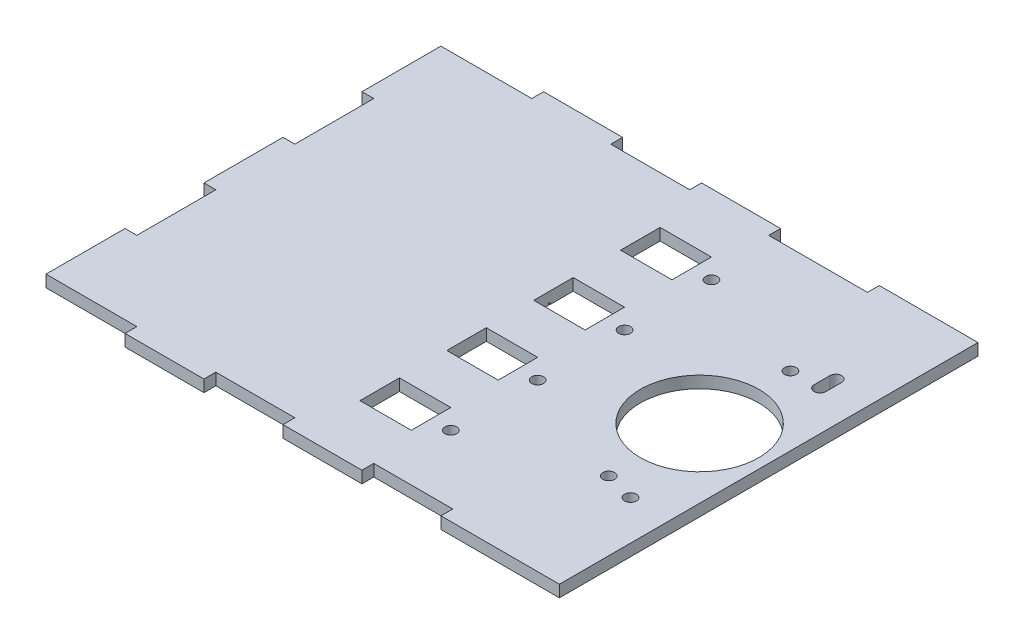
from build123d import *

# Parameters (mm, degrees)
SKETCH1_W            = 130
SKETCH1_H            = 100
BOSS_EXTRUDE1_DEPTH  = 3
SKETCH2_W            = 30
SKETCH2_H            = 3
BOSS_EXTRUDE2_DEPTH  = 3
SKETCH4_W            = 20
SKETCH4_H            = 3
BOSS_EXTRUDE3_DEPTH  = 3
SKETCH5_W            = 20
SKETCH5_H            = 3
BOSS_EXTRUDE4_DEPTH  = 3
SKETCH6_W            = 20
SKETCH6_H            = 3
BOSS_EXTRUDE5_DEPTH  = 3
SKETCH7_W            = 20
SKETCH7_H            = 3
BOSS_EXTRUDE6_DEPTH  = 3
SKETCH8_W            = 20
SKETCH8_H            = 3
BOSS_EXTRUDE7_DEPTH  = 3
SKETCH9_W            = 20
SKETCH9_H            = 3
BOSS_EXTRUDE8_DEPTH  = 3
SKETCH10_W           = 20
SKETCH10_H           = 3
BOSS_EXTRUDE9_DEPTH  = 3
SKETCH11_W           = 25
SKETCH11_H           = 3
BOSS_EXTRUDE10_DEPTH = 3
CUT_EXTRUDE1_DEPTH   = 0.5
SKETCH18_R           = 1.5
CUT_EXTRUDE2_DEPTH   = 10
SKETCH19_R           = 1.5
CUT_EXTRUDE3_DEPTH   = 10
SKETCH30_R           = 15
CUT_EXTRUDE9_DEPTH   = 3
SKETCH32_W           = 13
SKETCH32_H           = 10
CUT_EXTRUDE11_DEPTH  = 10
SKETCH34_R           = 1.5
CUT_EXTRUDE12_DEPTH  = 10
SKETCH35_R           = 1.5
CUT_EXTRUDE13_DEPTH  = 10


with BuildPart() as part:
    # Sketch1 → Boss-Extrude1 (new body)
    with BuildSketch(Plane(origin=(0, 0, 0), x_dir=(1, 0, 0), z_dir=(0, 1, 0))):
        with Locations((65, 50)):
            Rectangle(SKETCH1_W, SKETCH1_H)
    extrude(amount=BOSS_EXTRUDE1_DEPTH)

    # Sketch2 → Boss-Extrude2 (add)
    with BuildSketch(Plane.XY):
        with Locations((115, 1.5)):
            Rectangle(SKETCH2_W, SKETCH2_H)
    extrude(amount=BOSS_EXTRUDE2_DEPTH)

    # Sketch4 → Boss-Extrude3 (add)
    with BuildSketch(Plane.XY):
        with Locations((70, 1.5)):
            Rectangle(SKETCH4_W, SKETCH4_H)
    extrude(amount=BOSS_EXTRUDE3_DEPTH)

    # Sketch5 → Boss-Extrude4 (add)
    with BuildSketch(Plane.XY):
        with Locations((30, 1.5)):
            Rectangle(SKETCH5_W, SKETCH5_H)
    extrude(amount=BOSS_EXTRUDE4_DEPTH)

    # Sketch6 → Boss-Extrude5 (add)
    with BuildSketch(Plane.ZY):
        with Locations((-10, 1.5)):
            Rectangle(SKETCH6_W, SKETCH6_H)
    extrude(amount=BOSS_EXTRUDE5_DEPTH)

    # Sketch7 → Boss-Extrude6 (add)
    with BuildSketch(Plane.ZY):
        with Locations((-50, 1.5)):
            Rectangle(SKETCH7_W, SKETCH7_H)
    extrude(amount=BOSS_EXTRUDE6_DEPTH)

    # Sketch8 → Boss-Extrude7 (add)
    with BuildSketch(Plane.ZY):
        with Locations((-90, 1.5)):
            Rectangle(SKETCH8_W, SKETCH8_H)
    extrude(amount=BOSS_EXTRUDE7_DEPTH)

    # Sketch9 → Boss-Extrude8 (add)
    with BuildSketch(Plane(origin=(0, 0, -100), x_dir=(-1, 0, 0), z_dir=(0, 0, -1))):
        with Locations((-30, 1.5)):
            Rectangle(SKETCH9_W, SKETCH9_H)
    extrude(amount=BOSS_EXTRUDE8_DEPTH)

    # Sketch10 → Boss-Extrude9 (add)
    with BuildSketch(Plane(origin=(0, 0, -100), x_dir=(-1, 0, 0), z_dir=(0, 0, -1))):
        with Locations((-70, 1.5)):
            Rectangle(SKETCH10_W, SKETCH10_H)
    extrude(amount=BOSS_EXTRUDE9_DEPTH)

    # Sketch11 → Boss-Extrude10 (add)
    with BuildSketch(Plane(origin=(0, 0, -100), x_dir=(-1, 0, 0), z_dir=(0, 0, -1))):
        with Locations((-117.5, 1.5)):
            Rectangle(SKETCH11_W, SKETCH11_H)
    extrude(amount=BOSS_EXTRUDE10_DEPTH)

    # Sketch14 → Cut-Extrude1 (cut)
    with BuildSketch(Plane.XZ):
        with BuildLine():
            Line((39.09778483, -56.542885003), (39.780677458, -56.542885003))
            add(Edge.make_bspline(
                [(39.780677458, -56.542885003), (39.814105936, -56.543060753), (39.878898647, -56.543401401), (39.973118088, -56.548684532), (40.061366899, -56.555888202), (40.143670671, -56.567318295), (40.219991374, -56.581110072), (40.290559011, -56.597811888), (40.355149183, -56.617838502), (40.43226192, -56.649684783), (40.520182581, -56.697007951), (40.615380973, -56.766936517), (40.696785213, -56.85246898), (40.76697153, -56.948951635), (40.82277265, -57.055087407), (40.863141947, -57.168346596), (40.888699822, -57.287268338), (40.891328256, -57.368911515), (40.892656625, -57.410172663)],
                knots=[0, 0, 0, 0, 0.00010027, 0.000194349, 0.000283026, 0.000365821, 0.000443519, 0.000515622, 0.000583254, 0.00064614, 0.000765662, 0.000881909, 0.000998927, 0.001118415, 0.001238844, 0.00135727, 0.001478274, 0.001601912, 0.001601912, 0.001601912, 0.001601912], degree=3))
            add(Edge.make_bspline(
                [(40.892656625, -57.410172663), (40.891563406, -57.448825219), (40.889415129, -57.524781136), (40.86887237, -57.635875245), (40.836711701, -57.741626464), (40.792006452, -57.841648849), (40.733904456, -57.933682463), (40.665046137, -58.018469729), (40.581969335, -58.092420786), (40.519726095, -58.133763688), (40.488109349, -58.154764009)],
                knots=[0, 0, 0, 0, 0.000115857, 0.00022767, 0.000337672, 0.000446877, 0.000555233, 0.000663318, 0.000773539, 0.000887324, 0.000887324, 0.000887324, 0.000887324], degree=3))
            add(Edge.make_bspline(
                [(40.488109349, -58.154764009), (40.527869777, -58.170029008), (40.603941324, -58.199234733), (40.708627336, -58.250870197), (40.798822181, -58.307032307), (40.875219327, -58.368364157), (40.940556982, -58.434472968), (40.997609924, -58.506328082), (41.046291298, -58.58486684), (41.088004222, -58.669270375), (41.120552978, -58.758676844), (41.144928882, -58.85224762), (41.158896331, -58.949647175), (41.160883973, -59.015932554), (41.161887394, -59.04939542)],
                knots=[0, 0, 0, 0, 0.000127722, 0.000244363, 0.000349599, 0.000445847, 0.000537565, 0.000627901, 0.000720503, 0.000814257, 0.000909859, 0.001005428, 0.001103887, 0.001204268, 0.001204268, 0.001204268, 0.001204268], degree=3))
            add(Edge.make_bspline(
                [(41.161887394, -59.04939542), (41.160910548, -59.083562292), (41.158988576, -59.15078657), (41.144808604, -59.249541704), (41.120799497, -59.343916651), (41.087728351, -59.434521834), (41.044566036, -59.521181968), (40.992038072, -59.603995232), (40.929406508, -59.682129563), (40.859343639, -59.756453186), (40.780081494, -59.823280973), (40.694565739, -59.88279668), (40.601719419, -59.931742742), (40.503067425, -59.972858763), (40.397503109, -60.004265962), (40.285500502, -60.026238536), (40.1671562, -60.041043573), (40.085946449, -60.042260778), (40.044299253, -60.042885003)],
                knots=[0, 0, 0, 0, 0.000102481, 0.000201635, 0.000298562, 0.000394165, 0.000490425, 0.000588455, 0.000687769, 0.000790423, 0.000894381, 0.000998232, 0.001102369, 0.001208616, 0.001318415, 0.001432129, 0.001550749, 0.00167562, 0.00167562, 0.00167562, 0.00167562], degree=3))
            Line((40.044299253, -60.042885003), (39.09778483, -60.042885003))
            Line((39.09778483, -60.042885003), (39.09778483, -56.542885003))
        make_face()
        with BuildLine():
            Line((39.411887394, -56.901859362), (39.411887394, -58.023654234))
            Line((39.411887394, -58.023654234), (39.622925054, -58.023654234))
            add(Edge.make_bspline(
                [(39.622925054, -58.023654234), (39.65377385, -58.023254311), (39.713380009, -58.022481578), (39.799699905, -58.020268061), (39.879824924, -58.014070017), (39.953616757, -58.007873755), (40.020959201, -57.997799168), (40.081703062, -57.985807045), (40.136801659, -57.97312414), (40.200341205, -57.951554653), (40.272414153, -57.919676978), (40.349247257, -57.870205141), (40.416981727, -57.811280788), (40.474178915, -57.743289827), (40.520990385, -57.668423641), (40.5535041, -57.58787676), (40.575551384, -57.503656628), (40.577542916, -57.445838375), (40.578554061, -57.416482759)],
                knots=[0, 0, 0, 0, 9.2559e-05, 0.000178842, 0.000258967, 0.000333616, 0.000400942, 0.000463093, 0.000519379, 0.000570374, 0.000664201, 0.000755025, 0.000843472, 0.000932526, 0.001020669, 0.001107124, 0.001192318, 0.001280185, 0.001280185, 0.001280185, 0.001280185], degree=3))
            add(Edge.make_bspline(
                [(40.578554061, -57.416482759), (40.57802788, -57.397056988), (40.576995721, -57.358951216), (40.568542418, -57.303401862), (40.554174844, -57.251158109), (40.53572055, -57.201503999), (40.509931862, -57.155992148), (40.479568398, -57.113048953), (40.442882708, -57.074136834), (40.401125395, -57.037767336), (40.353116772, -57.005522808), (40.298885481, -56.977282045), (40.237697804, -56.954541268), (40.170584949, -56.934625116), (40.096513861, -56.920636822), (40.016339308, -56.908983434), (39.929404589, -56.903050692), (39.869259486, -56.902265329), (39.838169445, -56.901859362)],
                knots=[0, 0, 0, 0, 5.8261e-05, 0.000114285, 0.000168029, 0.000220632, 0.000272728, 0.000324483, 0.000378062, 0.000432741, 0.000490301, 0.000551137, 0.000615721, 0.000685833, 0.000760908, 0.00084162, 0.000928788, 0.00102206, 0.00102206, 0.00102206, 0.00102206], degree=3))
            Line((39.838169445, -56.901859362), (39.411887394, -56.901859362))
        make_face(mode=Mode.SUBTRACT)
        with BuildLine():
            Line((39.411887394, -58.382628593), (39.411887394, -59.683910644))
            Line((39.411887394, -59.683910644), (39.859203099, -59.683910644))
            add(Edge.make_bspline(
                [(39.859203099, -59.683910644), (39.891222025, -59.683526897), (39.952934284, -59.682787274), (40.042035514, -59.680372719), (40.124618618, -59.674880444), (40.200306753, -59.666234594), (40.269917206, -59.656856145), (40.332614909, -59.644244864), (40.388908102, -59.629795903), (40.45418241, -59.607461731), (40.527685918, -59.57276526), (40.606896775, -59.520451034), (40.677322993, -59.458127726), (40.737128252, -59.385996812), (40.786141241, -59.307565485), (40.821796696, -59.224420135), (40.843787552, -59.137934608), (40.846449722, -59.078967895), (40.84778483, -59.04939542)],
                knots=[0, 0, 0, 0, 9.6064e-05, 0.000185151, 0.000267373, 0.000344257, 0.000413665, 0.000478015, 0.000536005, 0.000587888, 0.000684801, 0.000778918, 0.000871787, 0.000965866, 0.001059062, 0.00114827, 0.001236355, 0.001324974, 0.001324974, 0.001324974, 0.001324974], degree=3))
            add(Edge.make_bspline(
                [(40.84778483, -59.04939542), (40.847508726, -59.030902079), (40.84696097, -58.994213697), (40.838700356, -58.940297878), (40.826686486, -58.888072005), (40.811155052, -58.837394264), (40.788535585, -58.789180888), (40.76212904, -58.742478328), (40.731167638, -58.697224849), (40.682923472, -58.640012595), (40.612751488, -58.574095583), (40.513044712, -58.50955808), (40.399672414, -58.457510273), (40.317444921, -58.435410797), (40.274968323, -58.423994779)],
                knots=[0, 0, 0, 0, 5.5429e-05, 0.000109963, 0.000163198, 0.000216191, 0.000268588, 0.000322593, 0.000377046, 0.000432793, 0.000546889, 0.000664343, 0.000787646, 0.000919405, 0.000919405, 0.000919405, 0.000919405], degree=3))
            add(Edge.make_bspline(
                [(40.274968323, -58.423994779), (40.257939228, -58.420539695), (40.221016635, -58.41304836), (40.160809055, -58.405140656), (40.092073186, -58.398095597), (40.014650309, -58.392884439), (39.928442468, -58.387497895), (39.833265549, -58.385403074), (39.729508234, -58.382903814), (39.657515862, -58.38272268), (39.620120567, -58.382628593)],
                knots=[0, 0, 0, 0, 5.2115e-05, 0.000112995, 0.000182062, 0.000259389, 0.000345767, 0.00044116, 0.000544948, 0.000657129, 0.000657129, 0.000657129, 0.000657129], degree=3))
            Line((39.620120567, -58.382628593), (39.411887394, -58.382628593))
        make_face(mode=Mode.SUBTRACT)
        with BuildLine():
            add(Edge.make_bspline(
                [(43.025469125, -57.4403209), (43.073460398, -57.441342791), (43.167559555, -57.44334647), (43.305367441, -57.464761436), (43.436912577, -57.4975088), (43.562698769, -57.542780362), (43.681115065, -57.603462313), (43.793886309, -57.675871604), (43.900703318, -57.761654198), (43.964726347, -57.828012266), (43.997223932, -57.861695099)],
                knots=[0, 0, 0, 0, 0.000143868, 0.000282091, 0.000417278, 0.000550139, 0.000682145, 0.000815559, 0.000951665, 0.001091969, 0.001091969, 0.001091969, 0.001091969], degree=3))
            add(Edge.make_bspline(
                [(43.997223932, -57.861695099), (44.025205886, -57.893909085), (44.080628267, -57.957713627), (44.151693986, -58.06116924), (44.212915546, -58.168309341), (44.261978507, -58.280556667), (44.30066353, -58.396931338), (44.328129227, -58.51783335), (44.344466162, -58.642995697), (44.346669128, -58.727999535), (44.34778483, -58.771050067)],
                knots=[0, 0, 0, 0, 0.000127922, 0.000253368, 0.000375813, 0.000497617, 0.000620225, 0.000743195, 0.000869033, 0.000998161, 0.000998161, 0.000998161, 0.000998161], degree=3))
            add(Edge.make_bspline(
                [(44.34778483, -58.771050067), (44.346803493, -58.814350125), (44.344864324, -58.899913058), (44.326520708, -59.025932424), (44.297989622, -59.148127246), (44.257157784, -59.26598594), (44.204799675, -59.379868768), (44.140908987, -59.489278317), (44.06503737, -59.59443045), (43.979033373, -59.694432288), (43.883981497, -59.786598503), (43.780865349, -59.866926773), (43.671711315, -59.935748297), (43.555067962, -59.991184713), (43.432000475, -60.034894413), (43.302243407, -60.065594429), (43.165998336, -60.084156113), (43.072971115, -60.086539687), (43.025469125, -60.087756798)],
                knots=[0, 0, 0, 0, 0.000129829, 0.000256548, 0.000381202, 0.000505812, 0.000630045, 0.000756669, 0.000885282, 0.001018518, 0.001151902, 0.001281775, 0.001409974, 0.001538236, 0.001668405, 0.001801048, 0.001937587, 0.002080055, 0.002080055, 0.002080055, 0.002080055], degree=3))
            add(Edge.make_bspline(
                [(43.025469125, -60.087756798), (42.977734405, -60.086535602), (42.884243546, -60.084143827), (42.747517564, -60.065666544), (42.617527945, -60.034908562), (42.494299346, -59.991041069), (42.377154499, -59.935746525), (42.267368002, -59.867134836), (42.164168087, -59.78657468), (42.069096102, -59.694438743), (41.983097497, -59.594428787), (41.907224489, -59.489278749), (41.843334162, -59.379868655), (41.790975959, -59.26598597), (41.750144146, -59.148127238), (41.721613053, -59.025932426), (41.703269438, -58.899913057), (41.70133027, -58.814350124), (41.700348932, -58.771050067)],
                knots=[0, 0, 0, 0, 0.000143168, 0.000280402, 0.000413045, 0.000543214, 0.000672108, 0.000800903, 0.000930775, 0.00106416, 0.001197395, 0.001326009, 0.001452632, 0.001576866, 0.001701476, 0.00182613, 0.001952849, 0.002082678, 0.002082678, 0.002082678, 0.002082678], degree=3))
            add(Edge.make_bspline(
                [(41.700348932, -58.771050067), (41.701472243, -58.728233521), (41.703696204, -58.643464119), (41.720016713, -58.518537058), (41.74737527, -58.397839669), (41.786106666, -58.281914193), (41.835621857, -58.170158757), (41.895983145, -58.062753926), (41.967773778, -57.959766125), (42.022975729, -57.896044045), (42.05090983, -57.863798464)],
                knots=[0, 0, 0, 0, 0.000128428, 0.000254265, 0.000377235, 0.000499178, 0.000620341, 0.000743397, 0.000868267, 0.000996189, 0.000996189, 0.000996189, 0.000996189], degree=3))
            add(Edge.make_bspline(
                [(42.05090983, -57.863798464), (42.083358421, -57.829823525), (42.147174285, -57.763005829), (42.254523012, -57.677473305), (42.367016834, -57.603557231), (42.48674176, -57.544081016), (42.612424618, -57.497242498), (42.74464386, -57.464676983), (42.882919376, -57.443423628), (42.977478997, -57.44136545), (43.025469125, -57.4403209)],
                knots=[0, 0, 0, 0, 0.000140798, 0.000276904, 0.000410699, 0.000543958, 0.000677061, 0.000812248, 0.000951858, 0.001095726, 0.001095726, 0.001095726, 0.001095726], degree=3))
        make_face()
        with BuildLine():
            add(Edge.make_bspline(
                [(43.024066881, -57.754423464), (42.99012927, -57.755388056), (42.923130141, -57.757292339), (42.824510556, -57.771776243), (42.729570403, -57.794723747), (42.638129558, -57.827327804), (42.550496386, -57.869426703), (42.466586984, -57.921135063), (42.386154544, -57.981768019), (42.31077248, -58.051230691), (42.241590168, -58.127109685), (42.181112192, -58.207958044), (42.129687085, -58.292464391), (42.086846926, -58.380716602), (42.054939738, -58.473609016), (42.031766716, -58.570089647), (42.017296475, -58.670355063), (42.015410097, -58.738516082), (42.014451497, -58.773153432)],
                knots=[0, 0, 0, 0, 0.000101781, 0.000200935, 0.000298373, 0.000394396, 0.000491609, 0.000589491, 0.000689611, 0.000793323, 0.000896562, 0.000997243, 0.001095722, 0.001192936, 0.001290943, 0.001389744, 0.001490285, 0.001594167, 0.001594167, 0.001594167, 0.001594167], degree=3))
            add(Edge.make_bspline(
                [(42.014451497, -58.773153432), (42.01605832, -58.81790546), (42.019247565, -58.906729865), (42.045182801, -59.037540988), (42.088569081, -59.16312284), (42.147156361, -59.282739226), (42.220562579, -59.393411504), (42.307049646, -59.492082988), (42.405689346, -59.5772688), (42.515305847, -59.647949645), (42.633660164, -59.704109401), (42.758916486, -59.743908377), (42.88955718, -59.769780069), (42.978837911, -59.772351543), (43.024066881, -59.773654234)],
                knots=[0, 0, 0, 0, 0.000134178, 0.000266319, 0.000398243, 0.00053182, 0.000664828, 0.000795487, 0.000924236, 0.001054533, 0.001185628, 0.001316003, 0.001448011, 0.001583547, 0.001583547, 0.001583547, 0.001583547], degree=3))
            add(Edge.make_bspline(
                [(43.024066881, -59.773654234), (43.06929325, -59.772343953), (43.158568846, -59.769757497), (43.289028023, -59.744038677), (43.413941995, -59.703935016), (43.532173382, -59.648012806), (43.641739986, -59.577000391), (43.741089107, -59.492564014), (43.826837718, -59.393150163), (43.900171323, -59.282592634), (43.959718066, -59.163308282), (44.002901268, -59.03751781), (44.028898853, -58.906735768), (44.032079682, -58.817907437), (44.033682266, -58.773153432)],
                knots=[0, 0, 0, 0, 0.000135536, 0.000267545, 0.000397252, 0.000528347, 0.000658644, 0.000787925, 0.000918122, 0.00105113, 0.001185017, 0.001316942, 0.001449082, 0.00158326, 0.00158326, 0.00158326, 0.00158326], degree=3))
            add(Edge.make_bspline(
                [(44.033682266, -58.773153432), (44.032723996, -58.738515875), (44.030838267, -58.670354449), (44.016363302, -58.570091995), (43.993207763, -58.473600399), (43.961236145, -58.380748395), (43.918582131, -58.292235891), (43.866165338, -58.208206164), (43.805934313, -58.126829618), (43.735917192, -58.051475977), (43.660613814, -57.981740941), (43.580148776, -57.921111551), (43.496363797, -57.869653956), (43.408985215, -57.826967715), (43.317532647, -57.795020375), (43.222725518, -57.771643743), (43.124526708, -57.757353547), (43.057767665, -57.755406405), (43.024066881, -57.754423464)],
                knots=[0, 0, 0, 0, 0.000103882, 0.000204424, 0.000303225, 0.000401232, 0.000498445, 0.000597291, 0.000697972, 0.000801684, 0.000905395, 0.001005516, 0.001103397, 0.001199979, 0.001296663, 0.00139342, 0.001492573, 0.001593654, 0.001593654, 0.001593654, 0.001593654], degree=3))
        make_face(mode=Mode.SUBTRACT)
        Polygon((45.290092522, -56.453141413), (45.604195086, -56.453141413), (45.604195086, -57.485192695), (46.052913035, -57.485192695), (46.052913035, -57.799295259), (45.604195086, -57.799295259), (45.604195086, -60.042885003), (45.290092522, -60.042885003), (45.290092522, -57.799295259), (44.841374573, -57.799295259), (44.841374573, -57.485192695), (45.290092522, -57.485192695), align=None)
        Polygon((46.905477138, -56.453141413), (47.219579702, -56.453141413), (47.219579702, -57.485192695), (47.66829765, -57.485192695), (47.66829765, -57.799295259), (47.219579702, -57.799295259), (47.219579702, -60.042885003), (46.905477138, -60.042885003), (46.905477138, -57.799295259), (46.456759189, -57.799295259), (46.456759189, -57.485192695), (46.905477138, -57.485192695), align=None)
        with BuildLine():
            add(Edge.make_bspline(
                [(49.442135791, -57.4403209), (49.490127064, -57.441342791), (49.584226222, -57.44334647), (49.722034108, -57.464761436), (49.853579244, -57.4975088), (49.979365436, -57.542780362), (50.097781731, -57.603462313), (50.210552975, -57.675871604), (50.317369984, -57.761654198), (50.381393013, -57.828012266), (50.413890599, -57.861695099)],
                knots=[0, 0, 0, 0, 0.000143868, 0.000282091, 0.000417278, 0.000550139, 0.000682145, 0.000815559, 0.000951665, 0.001091969, 0.001091969, 0.001091969, 0.001091969], degree=3))
            add(Edge.make_bspline(
                [(50.413890599, -57.861695099), (50.441872553, -57.893909085), (50.497294933, -57.957713627), (50.568360652, -58.06116924), (50.629582212, -58.168309341), (50.678645173, -58.280556667), (50.717330197, -58.396931338), (50.744795893, -58.51783335), (50.761132828, -58.642995697), (50.763335795, -58.727999535), (50.764451497, -58.771050067)],
                knots=[0, 0, 0, 0, 0.000127922, 0.000253368, 0.000375813, 0.000497617, 0.000620225, 0.000743195, 0.000869033, 0.000998161, 0.000998161, 0.000998161, 0.000998161], degree=3))
            add(Edge.make_bspline(
                [(50.764451497, -58.771050067), (50.763470159, -58.814350125), (50.761530991, -58.899913058), (50.743187375, -59.025932424), (50.714656289, -59.148127246), (50.67382445, -59.26598594), (50.621466341, -59.379868768), (50.557575654, -59.489278317), (50.481704037, -59.59443045), (50.39570004, -59.694432288), (50.300648164, -59.786598503), (50.197532015, -59.866926773), (50.088377982, -59.935748297), (49.971734628, -59.991184713), (49.848667141, -60.034894413), (49.718910073, -60.065594429), (49.582665003, -60.084156113), (49.489637782, -60.086539687), (49.442135791, -60.087756798)],
                knots=[0, 0, 0, 0, 0.000129829, 0.000256548, 0.000381202, 0.000505812, 0.000630045, 0.000756669, 0.000885282, 0.001018518, 0.001151902, 0.001281775, 0.001409974, 0.001538236, 0.001668405, 0.001801048, 0.001937587, 0.002080055, 0.002080055, 0.002080055, 0.002080055], degree=3))
            add(Edge.make_bspline(
                [(49.442135791, -60.087756798), (49.394401072, -60.086535602), (49.300910212, -60.084143827), (49.16418423, -60.065666544), (49.034194611, -60.034908562), (48.910966013, -59.991041069), (48.793821166, -59.935746525), (48.684034669, -59.867134836), (48.580834753, -59.78657468), (48.485762769, -59.694438743), (48.399764164, -59.594428787), (48.323891155, -59.489278749), (48.260000829, -59.379868655), (48.207642625, -59.26598597), (48.166810812, -59.148127238), (48.13827972, -59.025932426), (48.119936105, -58.899913057), (48.117996937, -58.814350124), (48.117015599, -58.771050067)],
                knots=[0, 0, 0, 0, 0.000143168, 0.000280402, 0.000413045, 0.000543214, 0.000672108, 0.000800903, 0.000930775, 0.00106416, 0.001197395, 0.001326009, 0.001452632, 0.001576866, 0.001701476, 0.00182613, 0.001952849, 0.002082678, 0.002082678, 0.002082678, 0.002082678], degree=3))
            add(Edge.make_bspline(
                [(48.117015599, -58.771050067), (48.118138909, -58.728233521), (48.120362871, -58.643464119), (48.13668338, -58.518537058), (48.164041936, -58.397839669), (48.202773333, -58.281914193), (48.252288524, -58.170158757), (48.312649812, -58.062753926), (48.384440444, -57.959766125), (48.439642396, -57.896044045), (48.467576497, -57.863798464)],
                knots=[0, 0, 0, 0, 0.000128428, 0.000254265, 0.000377235, 0.000499178, 0.000620341, 0.000743397, 0.000868267, 0.000996189, 0.000996189, 0.000996189, 0.000996189], degree=3))
            add(Edge.make_bspline(
                [(48.467576497, -57.863798464), (48.500025088, -57.829823525), (48.563840951, -57.763005829), (48.671189679, -57.677473305), (48.7836835, -57.603557231), (48.903408426, -57.544081016), (49.029091284, -57.497242498), (49.161310527, -57.464676983), (49.299586042, -57.443423628), (49.394145663, -57.44136545), (49.442135791, -57.4403209)],
                knots=[0, 0, 0, 0, 0.000140798, 0.000276904, 0.000410699, 0.000543958, 0.000677061, 0.000812248, 0.000951858, 0.001095726, 0.001095726, 0.001095726, 0.001095726], degree=3))
        make_face()
        with BuildLine():
            add(Edge.make_bspline(
                [(49.440733548, -57.754423464), (49.406795936, -57.755388056), (49.339796808, -57.757292339), (49.241177223, -57.771776243), (49.146237069, -57.794723747), (49.054796225, -57.827327804), (48.967163053, -57.869426703), (48.88325365, -57.921135063), (48.80282121, -57.981768019), (48.727439147, -58.051230691), (48.658256835, -58.127109685), (48.597778858, -58.207958044), (48.546353752, -58.292464391), (48.503513593, -58.380716602), (48.471606405, -58.473609016), (48.448433382, -58.570089647), (48.433963142, -58.670355063), (48.432076763, -58.738516082), (48.431118163, -58.773153432)],
                knots=[0, 0, 0, 0, 0.000101781, 0.000200935, 0.000298373, 0.000394396, 0.000491609, 0.000589491, 0.000689611, 0.000793323, 0.000896562, 0.000997243, 0.001095722, 0.001192936, 0.001290943, 0.001389744, 0.001490285, 0.001594167, 0.001594167, 0.001594167, 0.001594167], degree=3))
            add(Edge.make_bspline(
                [(48.431118163, -58.773153432), (48.432724987, -58.81790546), (48.435914231, -58.906729865), (48.461849468, -59.037540988), (48.505235748, -59.16312284), (48.563823027, -59.282739226), (48.637229246, -59.393411504), (48.723716313, -59.492082988), (48.822356013, -59.5772688), (48.931972513, -59.647949645), (49.050326831, -59.704109401), (49.175583152, -59.743908377), (49.306223846, -59.769780069), (49.395504577, -59.772351543), (49.440733548, -59.773654234)],
                knots=[0, 0, 0, 0, 0.000134178, 0.000266319, 0.000398243, 0.00053182, 0.000664828, 0.000795487, 0.000924236, 0.001054533, 0.001185628, 0.001316003, 0.001448011, 0.001583547, 0.001583547, 0.001583547, 0.001583547], degree=3))
            add(Edge.make_bspline(
                [(49.440733548, -59.773654234), (49.485959917, -59.772343953), (49.575235513, -59.769757497), (49.70569469, -59.744038677), (49.830608661, -59.703935016), (49.948840049, -59.648012806), (50.058406652, -59.577000391), (50.157755774, -59.492564014), (50.243504385, -59.393150163), (50.31683799, -59.282592634), (50.376384732, -59.163308282), (50.419567934, -59.03751781), (50.44556552, -58.906735768), (50.448746349, -58.817907437), (50.450348932, -58.773153432)],
                knots=[0, 0, 0, 0, 0.000135536, 0.000267545, 0.000397252, 0.000528347, 0.000658644, 0.000787925, 0.000918122, 0.00105113, 0.001185017, 0.001316942, 0.001449082, 0.00158326, 0.00158326, 0.00158326, 0.00158326], degree=3))
            add(Edge.make_bspline(
                [(50.450348932, -58.773153432), (50.449390662, -58.738515875), (50.447504933, -58.670354449), (50.433029969, -58.570091995), (50.409874429, -58.473600399), (50.377902812, -58.380748395), (50.335248798, -58.292235891), (50.282832005, -58.208206164), (50.22260098, -58.126829618), (50.152583859, -58.051475977), (50.077280481, -57.981740941), (49.996815443, -57.921111551), (49.913030464, -57.869653956), (49.825651881, -57.826967715), (49.734199314, -57.795020375), (49.639392185, -57.771643743), (49.541193375, -57.757353547), (49.474434332, -57.755406405), (49.440733548, -57.754423464)],
                knots=[0, 0, 0, 0, 0.000103882, 0.000204424, 0.000303225, 0.000401232, 0.000498445, 0.000597291, 0.000697972, 0.000801684, 0.000905395, 0.001005516, 0.001103397, 0.001199979, 0.001296663, 0.00139342, 0.001492573, 0.001593654, 0.001593654, 0.001593654, 0.001593654], degree=3))
        make_face(mode=Mode.SUBTRACT)
        with BuildLine():
            Line((51.392656625, -57.485192695), (51.706759189, -57.485192695))
            Line((51.706759189, -57.485192695), (51.706759189, -57.929703913))
            add(Edge.make_bspline(
                [(51.706759189, -57.929703913), (51.735043139, -57.890816311), (51.789237898, -57.816303938), (51.878103551, -57.718113654), (51.966879663, -57.634785499), (52.030813045, -57.591042628), (52.061526817, -57.570028432)],
                knots=[0, 0, 0, 0, 0.000144152, 0.000276209, 0.000396804, 0.000508302, 0.000508302, 0.000508302, 0.000508302], degree=3))
            add(Edge.make_bspline(
                [(52.061526817, -57.570028432), (52.103391479, -57.550023067), (52.186389379, -57.510361854), (52.317808604, -57.470128295), (52.452283273, -57.445403193), (52.543091487, -57.44202182), (52.588770407, -57.4403209)],
                knots=[0, 0, 0, 0, 0.000139031, 0.000275633, 0.000410962, 0.000547939, 0.000547939, 0.000547939, 0.000547939], degree=3))
            add(Edge.make_bspline(
                [(52.588770407, -57.4403209), (52.619663403, -57.441366191), (52.680798982, -57.443434765), (52.771383072, -57.456894801), (52.859241684, -57.480160974), (52.943855714, -57.512568297), (53.023576393, -57.551814984), (53.096665591, -57.597864692), (53.162289799, -57.649561768), (53.22041585, -57.709240701), (53.272684876, -57.778577299), (53.320763722, -57.859441548), (53.365188935, -57.953649209), (53.389810243, -58.02201575), (53.402772811, -58.058009202)],
                knots=[0, 0, 0, 0, 9.2678e-05, 0.000183405, 0.000274048, 0.000364807, 0.000454797, 0.00054019, 0.000623517, 0.000704829, 0.000789387, 0.000883415, 0.000986597, 0.001101318, 0.001101318, 0.001101318, 0.001101318], degree=3))
            add(Edge.make_bspline(
                [(53.402772811, -58.058009202), (53.416484062, -58.033284782), (53.443465879, -57.984630597), (53.488771516, -57.915772335), (53.536239313, -57.851365543), (53.586273806, -57.791359119), (53.638698393, -57.736049388), (53.693759793, -57.685253487), (53.751144574, -57.638753273), (53.830936814, -57.584430114), (53.934749422, -57.526728932), (54.065637536, -57.476700488), (54.201787708, -57.44578436), (54.294205406, -57.442154087), (54.340873772, -57.4403209)],
                knots=[0, 0, 0, 0, 8.4789e-05, 0.000166854, 0.000247064, 0.000324714, 0.000401089, 0.000475513, 0.000549314, 0.000622436, 0.0007649, 0.000904487, 0.001041601, 0.001181469, 0.001181469, 0.001181469, 0.001181469], degree=3))
            add(Edge.make_bspline(
                [(54.340873772, -57.4403209), (54.383755235, -57.441938121), (54.467678421, -57.445103179), (54.589855687, -57.469956653), (54.703797492, -57.5126343), (54.809274568, -57.570867936), (54.904434382, -57.64404712), (54.987150691, -57.731115957), (55.056921054, -57.83145858), (55.102499694, -57.925850569), (55.133414958, -58.009185902), (55.152476193, -58.080192193), (55.169315888, -58.158343746), (55.183297133, -58.243734008), (55.193515685, -58.336664616), (55.201086401, -58.436983492), (55.206210474, -58.544768603), (55.206572546, -58.619134104), (55.206759189, -58.657468336)],
                knots=[0, 0, 0, 0, 0.000128581, 0.000251645, 0.00037211, 0.000492305, 0.000611786, 0.000730807, 0.000851198, 0.000976936, 0.001044145, 0.001117629, 0.001197252, 0.00128393, 0.001377074, 0.001477631, 0.001585715, 0.001700707, 0.001700707, 0.001700707, 0.001700707], degree=3))
            Line((55.206759189, -58.657468336), (55.206759189, -60.042885003))
            Line((55.206759189, -60.042885003), (54.892656625, -60.042885003))
            Line((54.892656625, -60.042885003), (54.892656625, -58.656066093))
            add(Edge.make_bspline(
                [(54.892656625, -58.656066093), (54.892578742, -58.623345519), (54.892429063, -58.560461552), (54.889735431, -58.470209101), (54.884660117, -58.387940743), (54.878725478, -58.313768655), (54.870481669, -58.247519867), (54.859835737, -58.189327448), (54.848558057, -58.138733637), (54.829822066, -58.082647589), (54.799874174, -58.020777379), (54.754256694, -57.954053803), (54.696786588, -57.895973003), (54.630426432, -57.845554686), (54.554877987, -57.804561045), (54.471613264, -57.775285035), (54.381149212, -57.757162157), (54.318526424, -57.755356141), (54.286186272, -57.754423464)],
                knots=[0, 0, 0, 0, 9.816e-05, 0.000188648, 0.000270826, 0.000345412, 0.000411852, 0.000470988, 0.000522857, 0.0005672, 0.000648106, 0.000728233, 0.000808554, 0.000892128, 0.000977461, 0.001065278, 0.001156029, 0.001252946, 0.001252946, 0.001252946, 0.001252946], degree=3))
            add(Edge.make_bspline(
                [(54.286186272, -57.754423464), (54.246516318, -57.755839622), (54.168113407, -57.758638487), (54.05366792, -57.78721236), (53.943696904, -57.830292611), (53.841481771, -57.892725068), (53.74745398, -57.967533432), (53.666554402, -58.056483028), (53.599722217, -58.157112954), (53.554468241, -58.250259657), (53.52587894, -58.333929101), (53.507002024, -58.407026473), (53.492318632, -58.49010804), (53.478548103, -58.582615531), (53.469560375, -58.685185712), (53.461392003, -58.797344113), (53.45757114, -58.919428072), (53.457036681, -59.004054761), (53.456759189, -59.047993176)],
                knots=[0, 0, 0, 0, 0.000118788, 0.00023477, 0.000351815, 0.000471937, 0.000592603, 0.000711217, 0.000831002, 0.000953929, 0.001020668, 0.001096002, 0.00118016, 0.001273662, 0.001376495, 0.001488939, 0.001611007, 0.001742825, 0.001742825, 0.001742825, 0.001742825], degree=3))
            Line((53.456759189, -59.047993176), (53.456759189, -60.042885003))
            Line((53.456759189, -60.042885003), (53.142656625, -60.042885003))
            Line((53.142656625, -60.042885003), (53.142656625, -58.742304073))
            add(Edge.make_bspline(
                [(53.142656625, -58.742304073), (53.142577194, -58.705610755), (53.142424377, -58.635016497), (53.139748059, -58.533782822), (53.134661438, -58.441701742), (53.128780889, -58.358880278), (53.120320711, -58.285468949), (53.110710949, -58.221074191), (53.099362338, -58.16585744), (53.080572453, -58.105294055), (53.051857985, -58.038573133), (53.005669723, -57.967432111), (52.948062143, -57.905164014), (52.880491267, -57.852005265), (52.804485585, -57.808063784), (52.720502184, -57.776404032), (52.629297271, -57.757979743), (52.566419565, -57.755631246), (52.534082907, -57.754423464)],
                knots=[0, 0, 0, 0, 0.000110078, 0.00021178, 0.000303758, 0.00038673, 0.000460827, 0.00052538, 0.000582037, 0.000629718, 0.00071543, 0.000799052, 0.000882908, 0.000968755, 0.001056067, 0.001145266, 0.001236843, 0.001333803, 0.001333803, 0.001333803, 0.001333803], degree=3))
            add(Edge.make_bspline(
                [(52.534082907, -57.754423464), (52.496066695, -57.755953924), (52.420301736, -57.759004077), (52.308999766, -57.786458351), (52.201514083, -57.829462425), (52.099559384, -57.889122245), (52.005885236, -57.963021323), (51.923876968, -58.049936219), (51.854934443, -58.148785252), (51.809202628, -58.240949769), (51.779704154, -58.322523044), (51.760108819, -58.391873992), (51.743269193, -58.46887424), (51.730755172, -58.553761351), (51.718674756, -58.645982445), (51.712844447, -58.745996935), (51.707172885, -58.853719022), (51.70690047, -58.928091568), (51.706759189, -58.966663048)],
                knots=[0, 0, 0, 0, 0.000113893, 0.000226985, 0.000341817, 0.000460265, 0.000580056, 0.000698595, 0.000817435, 0.000940348, 0.001005999, 0.001077458, 0.001156396, 0.001242271, 0.001334801, 0.001435306, 0.00154269, 0.001658383, 0.001658383, 0.001658383, 0.001658383], degree=3))
            Line((51.706759189, -58.966663048), (51.706759189, -60.042885003))
            Line((51.706759189, -60.042885003), (51.392656625, -60.042885003))
            Line((51.392656625, -60.042885003), (51.392656625, -57.485192695))
        make_face()
        with BuildLine():
            Line((57.225989958, -57.485192695), (57.540092522, -57.485192695))
            Line((57.540092522, -57.485192695), (57.540092522, -58.671490772))
            add(Edge.make_bspline(
                [(57.540092522, -58.671490772), (57.540234427, -58.706313521), (57.540505885, -58.772927809), (57.542346825, -58.868782996), (57.546676919, -58.956199709), (57.552090744, -59.035228445), (57.55905288, -59.105855837), (57.56733624, -59.167835194), (57.576594662, -59.221869378), (57.585657376, -59.254412734), (57.58987217, -59.269547663)],
                knots=[0, 0, 0, 0, 0.00010447, 0.000199845, 0.000287586, 0.000367011, 0.000437473, 0.000500438, 0.00055462, 0.000601725, 0.000601725, 0.000601725, 0.000601725], degree=3))
            add(Edge.make_bspline(
                [(57.58987217, -59.269547663), (57.596633625, -59.288570534), (57.610015966, -59.326220795), (57.634289449, -59.3806098), (57.664317786, -59.430985083), (57.697177614, -59.479289156), (57.735077021, -59.524091142), (57.777536493, -59.565315386), (57.82313473, -59.604519477), (57.890889753, -59.650904269), (57.983549019, -59.700619599), (58.105201774, -59.743515418), (58.237106, -59.769151238), (58.328270719, -59.772125493), (58.37512858, -59.773654234)],
                knots=[0, 0, 0, 0, 6.0561e-05, 0.000119863, 0.000178304, 0.000236261, 0.000294971, 0.000353969, 0.000413668, 0.000475127, 0.000599968, 0.00072792, 0.000860749, 0.001001226, 0.001001226, 0.001001226, 0.001001226], degree=3))
            add(Edge.make_bspline(
                [(58.37512858, -59.773654234), (58.421982088, -59.772092985), (58.512634956, -59.769072258), (58.643089925, -59.744288719), (58.76234134, -59.70288303), (58.869192291, -59.645075618), (58.963158131, -59.574333556), (59.04146255, -59.491324747), (59.106069804, -59.39867536), (59.134279225, -59.329551081), (59.14846592, -59.294788048)],
                knots=[0, 0, 0, 0, 0.000140477, 0.000271796, 0.000396637, 0.000517726, 0.000634816, 0.00074789, 0.000858929, 0.000971266, 0.000971266, 0.000971266, 0.000971266], degree=3))
            add(Edge.make_bspline(
                [(59.14846592, -59.294788048), (59.15266015, -59.280821749), (59.161932568, -59.249945674), (59.17189492, -59.197565925), (59.180869381, -59.135101321), (59.188532557, -59.062143112), (59.19399772, -58.97888196), (59.196943746, -58.885343883), (59.200272022, -58.781822523), (59.200322538, -58.709354764), (59.200348932, -58.671490772)],
                knots=[0, 0, 0, 0, 4.3723e-05, 9.6661e-05, 0.000159723, 0.000233047, 0.000316669, 0.000409984, 0.000513788, 0.000627372, 0.000627372, 0.000627372, 0.000627372], degree=3))
            Line((59.200348932, -58.671490772), (59.200348932, -57.485192695))
            Line((59.200348932, -57.485192695), (59.514451497, -57.485192695))
            Line((59.514451497, -57.485192695), (59.514451497, -58.730385003))
            add(Edge.make_bspline(
                [(59.514451497, -58.730385003), (59.514009802, -58.772692174), (59.513152853, -58.854773874), (59.50764551, -58.974057986), (59.498195897, -59.085220231), (59.483853212, -59.18831945), (59.466987538, -59.283276932), (59.445231265, -59.370214378), (59.419253027, -59.448863932), (59.389947512, -59.520605709), (59.355325644, -59.585652603), (59.318498624, -59.64738842), (59.275973852, -59.704281355), (59.231203618, -59.759163492), (59.181401962, -59.80930502), (59.127502103, -59.855856495), (59.070262683, -59.899529527), (59.008413485, -59.938620807), (58.942857422, -59.973837452), (58.873513565, -60.00505353), (58.799532567, -60.029756107), (58.72186893, -60.051066773), (58.640142151, -60.067781242), (58.554431018, -60.079567809), (58.464764401, -60.08679314), (58.403654942, -60.087430185), (58.372324093, -60.087756798)],
                knots=[0, 0, 0, 0, 0.00012692, 0.000246243, 0.000358153, 0.000461473, 0.000558423, 0.000647357, 0.000730057, 0.000806749, 0.000879504, 0.000950929, 0.001022168, 0.001092368, 0.001163264, 0.001233837, 0.001305913, 0.001379045, 0.001453076, 0.001529034, 0.001606858, 0.001686798, 0.001770538, 0.001856901, 0.001946219, 0.002040193, 0.002040193, 0.002040193, 0.002040193], degree=3))
            add(Edge.make_bspline(
                [(58.372324093, -60.087756798), (58.341227579, -60.087417091), (58.280120034, -60.086749534), (58.190448789, -60.079607727), (58.104500183, -60.067799556), (58.022579784, -60.050944339), (57.944605387, -60.029905269), (57.870261147, -60.004901733), (57.800417584, -59.973821252), (57.73423558, -59.938843694), (57.672233192, -59.899278419), (57.614124614, -59.855910379), (57.559987761, -59.808804316), (57.509810693, -59.758156959), (57.464297717, -59.703340022), (57.422881675, -59.644794462), (57.38492497, -59.583100374), (57.35057218, -59.517037211), (57.321060424, -59.444465201), (57.295005178, -59.364168104), (57.27369454, -59.275265587), (57.256352071, -59.177833659), (57.242400631, -59.072338617), (57.232714489, -58.958170202), (57.227298658, -58.83560651), (57.226435596, -58.75095662), (57.225989958, -58.707247984)],
                knots=[0, 0, 0, 0, 9.3273e-05, 0.00018329, 0.000269653, 0.000353393, 0.000434009, 0.000511834, 0.000588433, 0.000663082, 0.000736214, 0.00080885, 0.000880413, 0.000951309, 0.001022496, 0.001093894, 0.001166283, 0.00123966, 0.001317, 0.001401032, 0.001492689, 0.001591018, 0.001697812, 0.001811817, 0.001934642, 0.002065769, 0.002065769, 0.002065769, 0.002065769], degree=3))
            Line((57.225989958, -58.707247984), (57.225989958, -57.485192695))
        make_face()
        with BuildLine():
            Line((60.232400214, -57.485192695), (60.546502779, -57.485192695))
            Line((60.546502779, -57.485192695), (60.546502779, -57.946530836))
            add(Edge.make_bspline(
                [(60.546502779, -57.946530836), (60.580040414, -57.904688113), (60.645121365, -57.82349085), (60.753505698, -57.716770275), (60.868049598, -57.62882505), (60.988051602, -57.558721256), (61.113674612, -57.50587463), (61.244152882, -57.467708699), (61.380267588, -57.444823871), (61.472832025, -57.44183364), (61.51965983, -57.4403209)],
                knots=[0, 0, 0, 0, 0.000160777, 0.000311994, 0.000455029, 0.000592958, 0.000727738, 0.000862858, 0.001000022, 0.001140458, 0.001140458, 0.001140458, 0.001140458], degree=3))
            add(Edge.make_bspline(
                [(61.51965983, -57.4403209), (61.566990464, -57.442066096), (61.659627932, -57.445481864), (61.794505993, -57.472498555), (61.920479387, -57.51864381), (62.037098943, -57.581855881), (62.142226156, -57.660462354), (62.234551007, -57.752040136), (62.310914255, -57.857376219), (62.362111618, -57.955099375), (62.395837266, -58.04178817), (62.417069603, -58.11603492), (62.435100584, -58.198753071), (62.450732332, -58.28969266), (62.461309444, -58.38949085), (62.469651736, -58.497738542), (62.47563043, -58.614400673), (62.475867637, -58.6950873), (62.475989958, -58.736695099)],
                knots=[0, 0, 0, 0, 0.00014192, 0.000277771, 0.000410631, 0.000543023, 0.000674273, 0.000803173, 0.000931629, 0.001063031, 0.00113295, 0.001210382, 0.001294414, 0.001386856, 0.001487045, 0.001595345, 0.001712567, 0.001837375, 0.001837375, 0.001837375, 0.001837375], degree=3))
            Line((62.475989958, -58.736695099), (62.475989958, -60.042885003))
            Line((62.475989958, -60.042885003), (62.161887394, -60.042885003))
            Line((62.161887394, -60.042885003), (62.161887394, -58.839760003))
            add(Edge.make_bspline(
                [(62.161887394, -58.839760003), (62.161694186, -58.804937558), (62.161324612, -58.738328147), (62.160158965, -58.642959124), (62.157349159, -58.556472546), (62.153400846, -58.479075178), (62.147621815, -58.410841342), (62.141599184, -58.351632065), (62.134234207, -58.301522522), (62.127671294, -58.27135744), (62.124727939, -58.257828913)],
                knots=[0, 0, 0, 0, 0.00010447, 0.000199832, 0.000286116, 0.000364054, 0.000432294, 0.000491525, 0.000542592, 0.000584118, 0.000584118, 0.000584118, 0.000584118], degree=3))
            add(Edge.make_bspline(
                [(62.124727939, -58.257828913), (62.114102407, -58.218117728), (62.093651547, -58.141685984), (62.043117564, -58.038011631), (61.979303383, -57.949813443), (61.901405533, -57.877636721), (61.810176458, -57.821465885), (61.705869315, -57.78249193), (61.589490674, -57.758115661), (61.507636292, -57.755688529), (61.46497233, -57.754423464)],
                knots=[0, 0, 0, 0, 0.000123096, 0.000236922, 0.000343781, 0.000447968, 0.000553428, 0.000663063, 0.000780492, 0.000908329, 0.000908329, 0.000908329, 0.000908329], degree=3))
            add(Edge.make_bspline(
                [(61.46497233, -57.754423464), (61.439704646, -57.754899469), (61.389700553, -57.75584147), (61.315550581, -57.765292768), (61.243626408, -57.780751224), (61.173206199, -57.801619861), (61.105698405, -57.83028213), (61.038934114, -57.862811501), (60.97542735, -57.903359713), (60.913823953, -57.948550334), (60.856511145, -57.998629541), (60.803182807, -58.051474051), (60.755644787, -58.107749655), (60.712576111, -58.166549603), (60.675397848, -58.228681441), (60.64294476, -58.293545747), (60.615409065, -58.361227896), (60.601726373, -58.408202957), (60.594880182, -58.431707118)],
                knots=[0, 0, 0, 0, 7.5773e-05, 0.000149953, 0.000223797, 0.000296325, 0.00036989, 0.000443574, 0.000518859, 0.000595564, 0.000672601, 0.000746967, 0.000820581, 0.000893366, 0.000965391, 0.001037508, 0.001110807, 0.001184211, 0.001184211, 0.001184211, 0.001184211], degree=3))
            add(Edge.make_bspline(
                [(60.594880182, -58.431707118), (60.590940534, -58.448962321), (60.582364125, -58.486525996), (60.573100945, -58.548170415), (60.56469337, -58.61948039), (60.557656411, -58.700372707), (60.553350995, -58.791130582), (60.548656598, -58.89136642), (60.546947537, -59.001479908), (60.546655183, -59.078141601), (60.546502779, -59.118105355)],
                knots=[0, 0, 0, 0, 5.3082e-05, 0.000115557, 0.000186868, 0.0002685, 0.000359077, 0.000459426, 0.000569522, 0.000689416, 0.000689416, 0.000689416, 0.000689416], degree=3))
            Line((60.546502779, -59.118105355), (60.546502779, -60.042885003))
            Line((60.546502779, -60.042885003), (60.232400214, -60.042885003))
            Line((60.232400214, -60.042885003), (60.232400214, -57.485192695))
        make_face()
        with BuildLine():
            Line((65.796502779, -56.453141413), (65.796502779, -60.042885003))
            Line((65.796502779, -60.042885003), (65.482400214, -60.042885003))
            Line((65.482400214, -60.042885003), (65.482400214, -59.60047715))
            add(Edge.make_bspline(
                [(65.482400214, -59.60047715), (65.446981424, -59.640516744), (65.377861209, -59.718654515), (65.262420091, -59.820736688), (65.140051913, -59.905115009), (65.011350592, -59.973264925), (64.876432348, -60.024456981), (64.735596261, -60.060843141), (64.58878488, -60.084236976), (64.488532525, -60.086572998), (64.43772874, -60.087756798)],
                knots=[0, 0, 0, 0, 0.000160263, 0.000312755, 0.000460949, 0.000605216, 0.000748578, 0.000892786, 0.001041028, 0.001193333, 0.001193333, 0.001193333, 0.001193333], degree=3))
            add(Edge.make_bspline(
                [(64.43772874, -60.087756798), (64.392560786, -60.086530425), (64.303487581, -60.084111965), (64.172458504, -60.065349661), (64.046366255, -60.03521904), (63.925091682, -59.99331815), (63.809419537, -59.937737329), (63.69835944, -59.871196081), (63.592486748, -59.791955251), (63.493415209, -59.701367222), (63.402183209, -59.602972235), (63.322121936, -59.498026688), (63.255368856, -59.386984384), (63.199548775, -59.27125123), (63.156552431, -59.149936311), (63.126578797, -59.023459143), (63.10783835, -58.891969269), (63.105420889, -58.802429746), (63.104195086, -58.757027631)],
                knots=[0, 0, 0, 0, 0.000135464, 0.00026714, 0.000396211, 0.000523931, 0.000651257, 0.000780517, 0.000911767, 0.001047265, 0.00118272, 0.001313831, 0.001442491, 0.001570752, 0.001698704, 0.001827775, 0.001960146, 0.00209631, 0.00209631, 0.00209631, 0.00209631], degree=3))
            add(Edge.make_bspline(
                [(63.104195086, -58.757027631), (63.105448058, -58.712563928), (63.107925114, -58.624661584), (63.126378334, -58.495382886), (63.157409343, -58.370864625), (63.200957191, -58.251507682), (63.256799146, -58.137167632), (63.324727233, -58.027763607), (63.404746357, -57.92299421), (63.496998764, -57.825322983), (63.596933535, -57.735102369), (63.703842265, -57.656693323), (63.815065547, -57.588976474), (63.932328557, -57.535322998), (64.053895662, -57.491913893), (64.180849108, -57.461880925), (64.312660687, -57.444183604), (64.402151179, -57.44162084), (64.447544445, -57.4403209)],
                knots=[0, 0, 0, 0, 0.000133363, 0.00026365, 0.000390846, 0.000517716, 0.000644083, 0.000771912, 0.000903449, 0.001038867, 0.001174416, 0.001306792, 0.001436052, 0.00156435, 0.001692963, 0.001822716, 0.001954992, 0.002091156, 0.002091156, 0.002091156, 0.002091156], degree=3))
            add(Edge.make_bspline(
                [(64.447544445, -57.4403209), (64.499761253, -57.441887996), (64.602257044, -57.444964032), (64.752155565, -57.470670399), (64.893943176, -57.513833277), (65.028436163, -57.572924558), (65.154832723, -57.649725309), (65.274059364, -57.742476757), (65.384042687, -57.853803903), (65.449114509, -57.937415477), (65.482400214, -57.980184682)],
                knots=[0, 0, 0, 0, 0.000156576, 0.000307342, 0.000454614, 0.000600266, 0.00074684, 0.00089719, 0.001052366, 0.001214863, 0.001214863, 0.001214863, 0.001214863], degree=3))
            Line((65.482400214, -57.980184682), (65.482400214, -56.453141413))
            Line((65.482400214, -56.453141413), (65.796502779, -56.453141413))
        make_face()
        with BuildLine():
            add(Edge.make_bspline(
                [(64.451751176, -57.754423464), (64.405836838, -57.756057102), (64.315209238, -57.759281643), (64.182165236, -57.784455138), (64.054851822, -57.826339733), (63.933905748, -57.883621634), (63.821237531, -57.955650371), (63.72054386, -58.042771754), (63.631001159, -58.142608768), (63.555692895, -58.254710878), (63.494302398, -58.374888969), (63.451135366, -58.500513408), (63.422666118, -58.629318385), (63.419757598, -58.716681071), (63.41829765, -58.76053324)],
                knots=[0, 0, 0, 0, 0.000137677, 0.000271753, 0.000404561, 0.000538791, 0.000672205, 0.000804452, 0.00093703, 0.001073348, 0.00120849, 0.001340643, 0.001470999, 0.001602378, 0.001602378, 0.001602378, 0.001602378], degree=3))
            add(Edge.make_bspline(
                [(63.41829765, -58.76053324), (63.420162544, -58.804123347), (63.423885021, -58.891132703), (63.450635715, -59.02011328), (63.495515588, -59.145767322), (63.556757651, -59.267028315), (63.633444276, -59.379612416), (63.722332928, -59.481352538), (63.82428321, -59.568842127), (63.937210717, -59.6420797), (64.057818687, -59.701242221), (64.184652619, -59.742407861), (64.315328257, -59.768985641), (64.404180591, -59.772090118), (64.448946689, -59.773654234)],
                knots=[0, 0, 0, 0, 0.000130727, 0.000260941, 0.000393327, 0.000530037, 0.000667328, 0.000800955, 0.000934191, 0.001068956, 0.001203792, 0.001335934, 0.001468075, 0.001602253, 0.001602253, 0.001602253, 0.001602253], degree=3))
            add(Edge.make_bspline(
                [(64.448946689, -59.773654234), (64.494393192, -59.77199427), (64.584781778, -59.768692766), (64.718220486, -59.743411501), (64.847715449, -59.701642702), (64.971502677, -59.643743576), (65.086818808, -59.57198622), (65.190316686, -59.487979129), (65.277832654, -59.390275945), (65.352025264, -59.282899492), (65.410200681, -59.165187495), (65.45257674, -59.039853304), (65.477630646, -58.906892556), (65.480788375, -58.816028629), (65.482400214, -58.769647823)],
                knots=[0, 0, 0, 0, 0.000136278, 0.000271043, 0.000405851, 0.000543552, 0.000679927, 0.000812429, 0.000941985, 0.001072088, 0.00120284, 0.001334538, 0.001467925, 0.001607002, 0.001607002, 0.001607002, 0.001607002], degree=3))
            add(Edge.make_bspline(
                [(65.482400214, -58.769647823), (65.481440558, -58.734309993), (65.479551651, -58.66475396), (65.465121081, -58.562626442), (65.442166155, -58.464892716), (65.409819985, -58.371450027), (65.3673287, -58.282815011), (65.316080934, -58.198351251), (65.255175485, -58.11849804), (65.185592789, -58.044354969), (65.109427586, -57.976728507), (65.028833045, -57.916364266), (64.942854298, -57.866775493), (64.852937262, -57.825734222), (64.758925927, -57.793075072), (64.660055307, -57.771287378), (64.55737632, -57.756327057), (64.487330265, -57.755064676), (64.451751176, -57.754423464)],
                knots=[0, 0, 0, 0, 0.000105983, 0.000208608, 0.000308773, 0.00040678, 0.000504626, 0.000603105, 0.000702667, 0.00080535, 0.000907651, 0.001007914, 0.001106881, 0.00120477, 0.001304102, 0.001404791, 0.00150811, 0.001614764, 0.001614764, 0.001614764, 0.001614764], degree=3))
        make_face(mode=Mode.SUBTRACT)
        with BuildLine():
            Line((68.61361015, -59.235192695), (68.892656625, -59.38172715))
            add(Edge.make_bspline(
                [(68.892656625, -59.38172715), (68.870420029, -59.421170482), (68.827156421, -59.497911584), (68.752755673, -59.603343445), (68.674763601, -59.698191161), (68.589659633, -59.779920815), (68.499989954, -59.8511722), (68.405257299, -59.913510025), (68.304968481, -59.966628545), (68.199118756, -60.011381073), (68.086819205, -60.045790567), (67.967797689, -60.070094788), (67.841826193, -60.085118057), (67.755480013, -60.086863197), (67.7112664, -60.087756798)],
                knots=[0, 0, 0, 0, 0.000135759, 0.000264133, 0.000386579, 0.000503597, 0.000617365, 0.000729763, 0.000843304, 0.000957371, 0.001074023, 0.001195027, 0.001321389, 0.001453992, 0.001453992, 0.001453992, 0.001453992], degree=3))
            add(Edge.make_bspline(
                [(67.7112664, -60.087756798), (67.662124423, -60.086609622), (67.566262661, -60.084371816), (67.426722914, -60.065079351), (67.295343496, -60.033606993), (67.172131792, -59.989641451), (67.05738954, -59.932214127), (66.950888685, -59.862254645), (66.852069159, -59.78012239), (66.76404495, -59.685105947), (66.684801067, -59.58342399), (66.614875247, -59.477468105), (66.556417816, -59.367504881), (66.508865206, -59.254234357), (66.470460341, -59.138370463), (66.443693637, -59.018858996), (66.428263889, -58.896023411), (66.425899444, -58.812926076), (66.424707907, -58.771050067)],
                knots=[0, 0, 0, 0, 0.000147371, 0.000287478, 0.000421649, 0.000552053, 0.000679042, 0.000805636, 0.000933558, 0.00106351, 0.001193382, 0.001319977, 0.001443869, 0.001566405, 0.001688128, 0.001809576, 0.001933238, 0.002058864, 0.002058864, 0.002058864, 0.002058864], degree=3))
            add(Edge.make_bspline(
                [(66.424707907, -58.771050067), (66.425767048, -58.731755237), (66.427866126, -58.653878072), (66.441096914, -58.538612527), (66.464545207, -58.426584075), (66.496721531, -58.317699627), (66.538272777, -58.212141493), (66.589104996, -58.109845429), (66.649297374, -58.010920289), (66.695770048, -57.948517156), (66.719179061, -57.917083721)],
                knots=[0, 0, 0, 0, 0.000117891, 0.000233644, 0.000347498, 0.000460856, 0.000573868, 0.000687374, 0.000803169, 0.000920699, 0.000920699, 0.000920699, 0.000920699], degree=3))
            add(Edge.make_bspline(
                [(66.719179061, -57.917083721), (66.750886743, -57.879214851), (66.81329769, -57.8046767), (66.918854045, -57.706738375), (67.033154242, -57.624694599), (67.154765868, -57.556687463), (67.285102342, -57.505013816), (67.422411633, -57.466506234), (67.568257219, -57.444928223), (67.66796244, -57.441880389), (67.71897874, -57.4403209)],
                knots=[0, 0, 0, 0, 0.000148071, 0.000291452, 0.00043058, 0.000569298, 0.000708346, 0.00085021, 0.000996268, 0.001149307, 0.001149307, 0.001149307, 0.001149307], degree=3))
            add(Edge.make_bspline(
                [(67.71897874, -57.4403209), (67.771426345, -57.441674949), (67.874316591, -57.444331284), (68.024348712, -57.468957618), (68.166309429, -57.508010172), (68.300141933, -57.563163963), (68.425859794, -57.634323515), (68.542645844, -57.722465356), (68.652497356, -57.824883443), (68.716405935, -57.903646653), (68.748926657, -57.943726349)],
                knots=[0, 0, 0, 0, 0.000157241, 0.00030847, 0.000454763, 0.000598116, 0.000741606, 0.000886879, 0.001036172, 0.001190853, 0.001190853, 0.001190853, 0.001190853], degree=3))
            add(Edge.make_bspline(
                [(68.748926657, -57.943726349), (68.771053595, -57.97392993), (68.815160188, -58.034136049), (68.870407288, -58.132307206), (68.918364683, -58.235017801), (68.956697644, -58.343928098), (68.987737145, -58.457747678), (69.010193964, -58.577290223), (69.023363583, -58.702520134), (69.02595228, -58.787846689), (69.027272009, -58.831346541)],
                knots=[0, 0, 0, 0, 0.000112234, 0.000223721, 0.000337279, 0.000451932, 0.000569628, 0.000690912, 0.000816421, 0.00094695, 0.00094695, 0.00094695, 0.00094695], degree=3))
            Line((69.027272009, -58.831346541), (66.738810471, -58.831346541))
            add(Edge.make_bspline(
                [(66.738810471, -58.831346541), (66.740350077, -58.865047006), (66.743377651, -58.931317609), (66.757492794, -59.028288392), (66.779741568, -59.120661735), (66.811010631, -59.207744777), (66.848877476, -59.290674904), (66.895263193, -59.368836941), (66.950602747, -59.441874871), (67.012328446, -59.510442009), (67.081035542, -59.57150277), (67.153318289, -59.626154546), (67.230211854, -59.671960143), (67.311109937, -59.709140033), (67.395881722, -59.738246349), (67.484553918, -59.758114169), (67.576952034, -59.771421276), (67.639937768, -59.772900941), (67.67200358, -59.773654234)],
                knots=[0, 0, 0, 0, 0.000101159, 0.000198924, 0.000293472, 0.000385722, 0.000476069, 0.000566611, 0.000657757, 0.000750573, 0.000842919, 0.000933083, 0.001022062, 0.001110842, 0.001199752, 0.001290403, 0.001383113, 0.001479259, 0.001479259, 0.001479259, 0.001479259], degree=3))
            add(Edge.make_bspline(
                [(67.67200358, -59.773654234), (67.703354727, -59.773046177), (67.765561418, -59.771839676), (67.858202276, -59.760107765), (67.949341803, -59.741137489), (68.038602786, -59.715247499), (68.124173632, -59.683670647), (68.203419182, -59.64556779), (68.276299398, -59.603418043), (68.344416365, -59.555208368), (68.410487358, -59.496200181), (68.476029844, -59.42256446), (68.546306498, -59.335476932), (68.59029609, -59.269931266), (68.61361015, -59.235192695)],
                knots=[0, 0, 0, 0, 9.4016e-05, 0.000186545, 0.000279636, 0.000373054, 0.000465125, 0.000552934, 0.000636508, 0.000717442, 0.000802858, 0.000901616, 0.001012865, 0.001138311, 0.001138311, 0.001138311, 0.001138311], degree=3))
        make_face()
        with BuildLine():
            add(Edge.make_bspline(
                [(68.713169445, -58.517243977), (68.701672821, -58.475581104), (68.679545519, -58.395393483), (68.633309155, -58.284352592), (68.581237614, -58.185664691), (68.519615883, -58.100085058), (68.449797157, -58.024081545), (68.369151974, -57.95766296), (68.278716081, -57.898245509), (68.17895694, -57.84809301), (68.073315155, -57.805403151), (67.962708963, -57.776778035), (67.849851175, -57.757168493), (67.773516889, -57.755342385), (67.735104541, -57.754423464)],
                knots=[0, 0, 0, 0, 0.000129543, 0.000249328, 0.000360065, 0.000463575, 0.000564789, 0.000668832, 0.000776175, 0.000888744, 0.001003316, 0.001117263, 0.001230914, 0.001346035, 0.001346035, 0.001346035, 0.001346035], degree=3))
            add(Edge.make_bspline(
                [(67.735104541, -57.754423464), (67.703755103, -57.755035136), (67.641783854, -57.756244282), (67.550482786, -57.767714411), (67.462803087, -57.786674256), (67.378097799, -57.812639213), (67.297476931, -57.847247815), (67.219282163, -57.887831042), (67.145501766, -57.937372626), (67.099360471, -57.975131481), (67.076050054, -57.994207118)],
                knots=[0, 0, 0, 0, 9.4016e-05, 0.000185849, 0.000275511, 0.000362884, 0.000451173, 0.00053836, 0.000626838, 0.000717174, 0.000717174, 0.000717174, 0.000717174], degree=3))
            add(Edge.make_bspline(
                [(67.076050054, -57.994207118), (67.059356772, -58.009301434), (67.025573638, -58.03984865), (66.980433117, -58.092477856), (66.937212644, -58.149229419), (66.897878991, -58.212274543), (66.861801405, -58.280895322), (66.828041427, -58.354512957), (66.797655015, -58.433686088), (66.780558905, -58.488858527), (66.771763195, -58.517243977)],
                knots=[0, 0, 0, 0, 6.7454e-05, 0.00013651, 0.000207604, 0.000281328, 0.000359112, 0.000440057, 0.000524171, 0.000613305, 0.000613305, 0.000613305, 0.000613305], degree=3))
            Line((66.771763195, -58.517243977), (68.713169445, -58.517243977))
        make_face(mode=Mode.SUBTRACT)
        with BuildLine():
            Line((69.565733548, -57.485192695), (69.879836112, -57.485192695))
            Line((69.879836112, -57.485192695), (69.879836112, -57.861695099))
            add(Edge.make_bspline(
                [(69.879836112, -57.861695099), (69.903024871, -57.826639271), (69.947373192, -57.759595271), (70.021086121, -57.67092597), (70.096589452, -57.597510924), (70.17424464, -57.539007405), (70.254622739, -57.495194286), (70.335959691, -57.463101251), (70.419535161, -57.444123936), (70.475697085, -57.441590277), (70.503834509, -57.4403209)],
                knots=[0, 0, 0, 0, 0.000126023, 0.000241017, 0.000345147, 0.000441342, 0.00053171, 0.000618946, 0.000702978, 0.000787349, 0.000787349, 0.000787349, 0.000787349], degree=3))
            add(Edge.make_bspline(
                [(70.503834509, -57.4403209), (70.525660836, -57.441511427), (70.570569921, -57.443961013), (70.638552511, -57.461171837), (70.708595963, -57.48864986), (70.75373835, -57.514490083), (70.777272009, -57.527961125)],
                knots=[0, 0, 0, 0, 6.5445e-05, 0.000134658, 0.00020926, 0.000290509, 0.000290509, 0.000290509, 0.000290509], degree=3))
            Line((70.777272009, -57.527961125), (70.604796048, -57.799996381))
            add(Edge.make_bspline(
                [(70.604796048, -57.799996381), (70.589687027, -57.793256115), (70.561007212, -57.7804618), (70.519052646, -57.765319789), (70.480371309, -57.756403874), (70.455727751, -57.755053156), (70.444239157, -57.754423464)],
                knots=[0, 0, 0, 0, 4.9621e-05, 9.4191e-05, 0.00013366, 0.000168129, 0.000168129, 0.000168129, 0.000168129], degree=3))
            add(Edge.make_bspline(
                [(70.444239157, -57.754423464), (70.419033423, -57.756103502), (70.367621033, -57.759530291), (70.292136534, -57.786469099), (70.218889328, -57.829994339), (70.160717666, -57.878265451), (70.115675413, -57.924813248), (70.083535188, -57.965461651), (70.054052441, -58.011040282), (70.02588222, -58.060769966), (70.000215926, -58.115499812), (69.976261257, -58.174683026), (69.954602394, -58.238388154), (69.94225215, -58.282770675), (69.935925856, -58.305505195)],
                knots=[0, 0, 0, 0, 7.549e-05, 0.000153978, 0.000237553, 0.000330197, 0.000379784, 0.000431685, 0.000485357, 0.000542493, 0.000603021, 0.000666557, 0.00073396, 0.000804745, 0.000804745, 0.000804745, 0.000804745], degree=3))
            add(Edge.make_bspline(
                [(69.935925856, -58.305505195), (69.931193462, -58.325782369), (69.92071157, -58.370694767), (69.910520033, -58.446043292), (69.900450515, -58.535066951), (69.893353896, -58.638013544), (69.886775854, -58.754625988), (69.883065772, -58.885081933), (69.879962631, -59.029515284), (69.879879564, -59.130489638), (69.879836112, -59.183309682)],
                knots=[0, 0, 0, 0, 6.2435e-05, 0.000138289, 0.000227871, 0.000331224, 0.000447781, 0.000578258, 0.000722716, 0.000881171, 0.000881171, 0.000881171, 0.000881171], degree=3))
            Line((69.879836112, -59.183309682), (69.879836112, -60.042885003))
            Line((69.879836112, -60.042885003), (69.565733548, -60.042885003))
            Line((69.565733548, -60.042885003), (69.565733548, -57.485192695))
        make_face()
    extrude(amount=-CUT_EXTRUDE1_DEPTH, mode=Mode.SUBTRACT)

    # Sketch18 → Cut-Extrude2 (cut)
    with BuildSketch(Plane(origin=(0, 3, 0), x_dir=(1, 0, 0), z_dir=(0, 1, 0))):
        with Locations((112.5, 73)):
            Circle(SKETCH18_R)
    extrude(amount=-CUT_EXTRUDE2_DEPTH, mode=Mode.SUBTRACT)

    # Sketch19 → Cut-Extrude3 (cut)
    with BuildSketch(Plane(origin=(0, 3, 0), x_dir=(1, 0, 0), z_dir=(0, 1, 0))):
        with Locations((112.5, 27)):
            Circle(SKETCH19_R)
    extrude(amount=-CUT_EXTRUDE3_DEPTH, mode=Mode.SUBTRACT)

    # Sketch30 → Cut-Extrude9 (cut)
    with BuildSketch(Plane(origin=(0, 3, 0), x_dir=(1, 0, 0), z_dir=(0, 1, 0))):
        with Locations((112.5, 50)):
            Circle(SKETCH30_R)
    extrude(amount=-CUT_EXTRUDE9_DEPTH, mode=Mode.SUBTRACT)

    # Sketch32 → Cut-Extrude11 (cut)
    with BuildSketch(Plane(origin=(0, 3, 0), x_dir=(1, 0, 0), z_dir=(0, 1, 0))):
        with Locations((71, 83)):
            Rectangle(SKETCH32_W, SKETCH32_H)
        with Locations((71, 61)):
            Rectangle(SKETCH32_W, SKETCH32_H)
        with Locations((71, 39)):
            Rectangle(SKETCH32_W, SKETCH32_H)
        with Locations((71, 17)):
            Rectangle(SKETCH32_W, SKETCH32_H)
    extrude(amount=-CUT_EXTRUDE11_DEPTH, mode=Mode.SUBTRACT)

    # Sketch34 → Cut-Extrude12 (cut)
    with BuildSketch(Plane(origin=(0, 3, 0), x_dir=(1, 0, 0), z_dir=(0, 1, 0))):
        with Locations((82.5, 83)):
            Circle(SKETCH34_R)
        with Locations((82.5, 61)):
            Circle(SKETCH34_R)
        with Locations((82.5, 39)):
            Circle(SKETCH34_R)
        with Locations((82.5, 17)):
            Circle(SKETCH34_R)
    extrude(amount=-CUT_EXTRUDE12_DEPTH, mode=Mode.SUBTRACT)

    # Sketch35 → Cut-Extrude13 (cut)
    with BuildSketch(Plane(origin=(0, 3, 0), x_dir=(1, 0, 0), z_dir=(0, 1, 0))):
        with Locations((120, 25)):
            Circle(SKETCH35_R)
        with BuildLine():
            Line((121.5, 73), (121.5, 77))
            ThreePointArc((121.5, 77), (120, 78.5), (118.5, 77))
            Line((118.5, 77), (118.5, 73))
            ThreePointArc((118.5, 73), (120, 71.5), (121.5, 73))
        make_face()
    extrude(amount=-CUT_EXTRUDE13_DEPTH, mode=Mode.SUBTRACT)


solid = part.part
